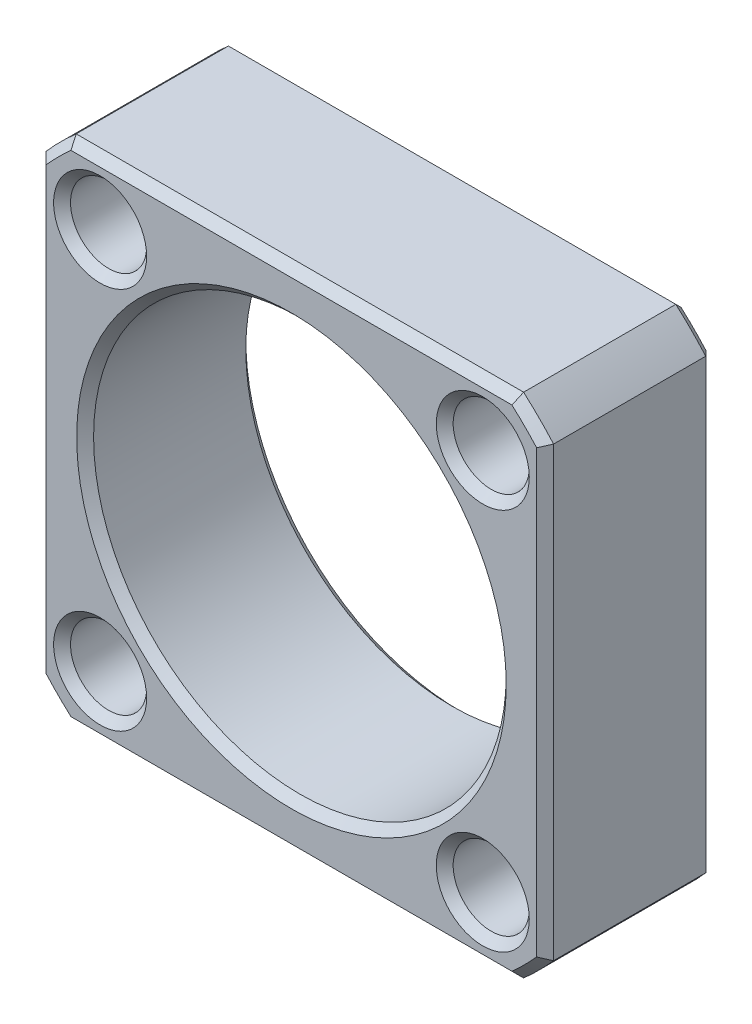
from build123d import *

# Parameters (mm, degrees)
SKETCH1_R           = 2.25
BOSS_EXTRUDE1_DEPTH = 10
SKETCH2_R           = 12.2
CUT_EXTRUDE3_DEPTH  = 11
CHAMFER1_SIZE       = 0.5


with BuildPart() as part:
    # Sketch1 → Boss-Extrude1 (new body)
    with BuildSketch(Plane.XY):
        with BuildLine():
            Line((-13.228756555, 15), (13.228756555, 15))
            ThreePointArc((13.228756555, 15), (14.142135624, 14.142135624), (15, 13.228756555))
            Line((15, 13.228756555), (15, -13.228756555))
            ThreePointArc((15, -13.228756555), (14.142135624, -14.142135624), (13.228756555, -15))
            Line((13.228756555, -15), (-13.228756555, -15))
            ThreePointArc((-13.228756555, -15), (-14.142135624, -14.142135624), (-15, -13.228756555))
            Line((-15, -13.228756555), (-15, 13.228756555))
            ThreePointArc((-15, 13.228756555), (-14.142135624, 14.142135624), (-13.228756555, 15))
        make_face()
        with Locations((-11.313708499, 11.313708499)):
            Circle(SKETCH1_R, mode=Mode.SUBTRACT)
        with Locations((11.313708499, 11.313708499)):
            Circle(SKETCH1_R, mode=Mode.SUBTRACT)
        with Locations((11.313708499, -11.313708499)):
            Circle(SKETCH1_R, mode=Mode.SUBTRACT)
        with Locations((-11.313708499, -11.313708499)):
            Circle(SKETCH1_R, mode=Mode.SUBTRACT)
    extrude(amount=BOSS_EXTRUDE1_DEPTH)

    # Sketch2 → Cut-Extrude3 (cut, through all)
    with BuildSketch(Plane.XY.offset(10)):
        Circle(SKETCH2_R)
    extrude(amount=-CUT_EXTRUDE3_DEPTH, mode=Mode.SUBTRACT)

    # Chamfer1
    chamfer1_edges = [part.edges().sort_by_distance(p)[0] for p in [
        (-14.142135624, -14.142135624, 10),
        (-15, 0, 0),
        (-14.142135624, 14.142135624, 0),
        (0, -15, 10),
        (14.142135624, -14.142135624, 10),
        (15, 0, 10),
        (-13.563708499, 11.313708499, 0),
        (-13.563708499, 11.313708499, 10),
        (14.142135624, 14.142135624, 10),
        (9.063708499, 11.313708499, 0),
        (9.063708499, 11.313708499, 10),
        (0, 15, 10),
        (9.063708499, -11.313708499, 0),
        (9.063708499, -11.313708499, 10),
        (-13.563708499, -11.313708499, 0),
        (-13.563708499, -11.313708499, 10),
        (-14.142135624, 14.142135624, 10),
        (-12.2, 0, 0),
        (-12.2, 0, 10),
        (-15, 0, 10),
        (0, 15, 0),
        (14.142135624, 14.142135624, 0),
        (15, 0, 0),
        (14.142135624, -14.142135624, 0),
        (0, -15, 0),
        (-14.142135624, -14.142135624, 0),
    ]]
    chamfer(chamfer1_edges, length=CHAMFER1_SIZE)


solid = part.part
